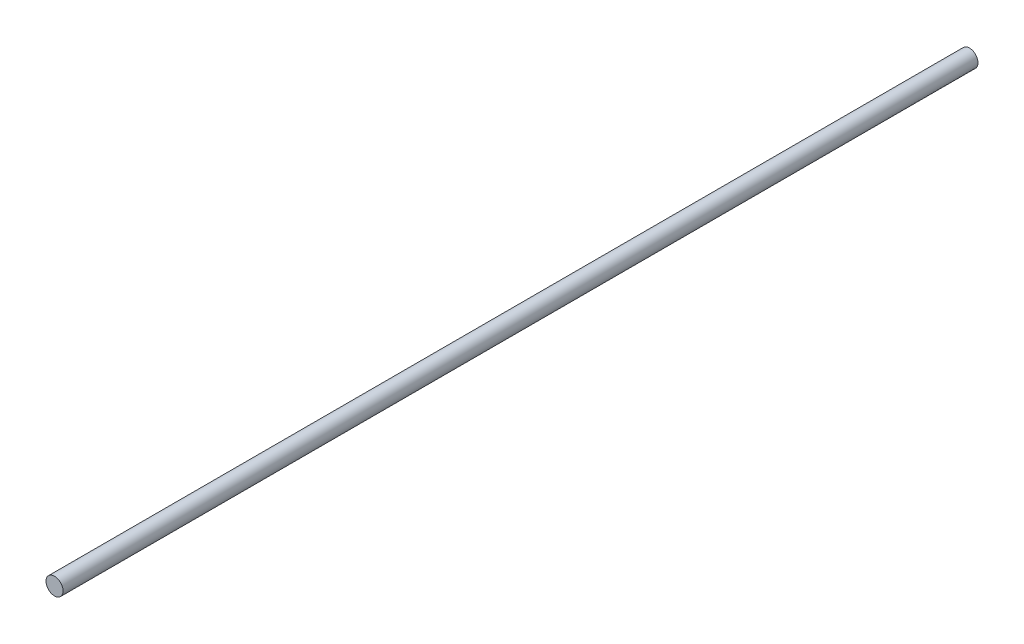
from build123d import *

# Parameters (mm, degrees)
SKETCH1_R           = 4.7625
BOSS_EXTRUDE1_DEPTH = 510


with BuildPart() as part:
    # Sketch1 → Boss-Extrude1 (new body)
    with BuildSketch(Plane.XY):
        Circle(SKETCH1_R)
    extrude(amount=-BOSS_EXTRUDE1_DEPTH)


solid = part.part
